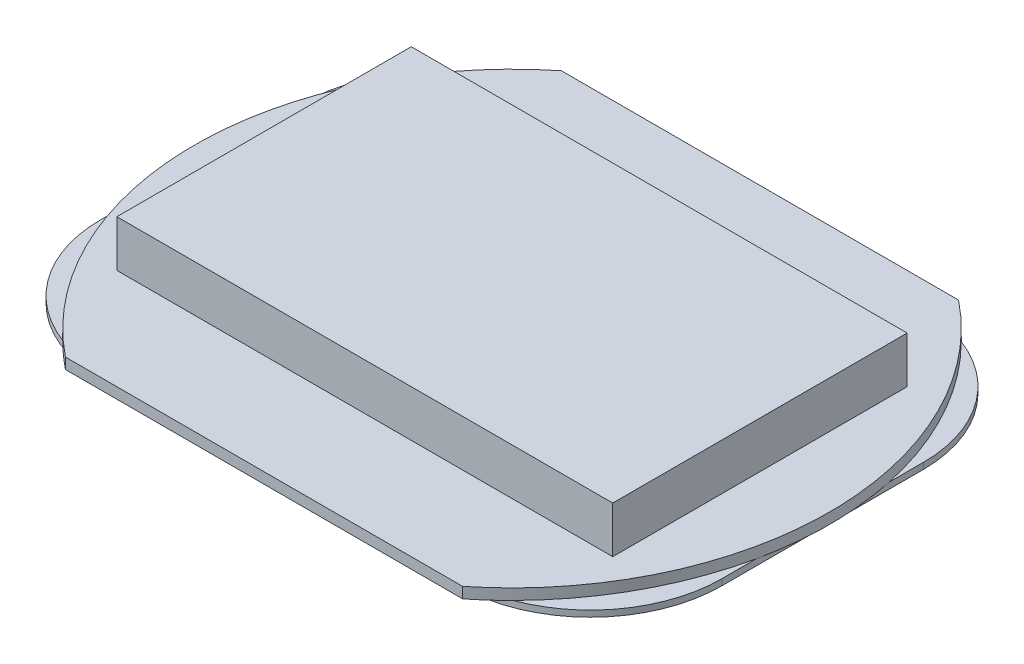
from build123d import *

# Parameters (mm, degrees)
EXTRUDE_1_DEPTH = 0.7
SKETCH_2_W      = 22
SKETCH_2_H      = 11
EXTRUDE_2_DEPTH = 0.4
SKETCH_3_W      = 32
SKETCH_3_H      = 19
EXTRUDE_3_DEPTH = 3


with BuildPart() as part:
    # Эскиз1 → Бобышка-Вытянуть1 (new body)
    with BuildSketch(Plane(origin=(0, 0, 0), x_dir=(1, 0, 0), z_dir=(0, 1, 0))):
        with BuildLine():
            Line((-12.816005618, 16), (12.816005618, 16))
            ThreePointArc((12.816005618, 16), (20.5, 0), (12.816005618, -16))
            Line((12.816005618, -16), (-12.816005618, -16))
            ThreePointArc((-12.816005618, -16), (-20.5, 0), (-12.816005618, 16))
        make_face()
    extrude(amount=EXTRUDE_1_DEPTH)

    # Эскиз2 → Бобышка-Вытянуть2 (add)
    with BuildSketch(Plane.XZ):
        with BuildLine():
            Line((-11.55, 15), (11.55, 15))
            ThreePointArc((11.55, 15), (17.56040764, 12.51040764), (20.05, 6.5))
            Line((20.05, 6.5), (20.05, -6.5))
            ThreePointArc((20.05, -6.5), (17.56040764, -12.51040764), (11.55, -15))
            Line((11.55, -15), (-11.55, -15))
            ThreePointArc((-11.55, -15), (-17.56040764, -12.51040764), (-20.05, -6.5))
            Line((-20.05, -6.5), (-20.05, 6.5))
            ThreePointArc((-20.05, 6.5), (-17.56040764, 12.51040764), (-11.55, 15))
        make_face()
        Rectangle(SKETCH_2_W, SKETCH_2_H, mode=Mode.SUBTRACT)
    extrude(amount=EXTRUDE_2_DEPTH)

    # Эскиз3 → Бобышка-Вытянуть3 (add)
    with BuildSketch(Plane(origin=(0, 0.7, 0), x_dir=(1, 0, 0), z_dir=(0, 1, 0))):
        Rectangle(SKETCH_3_W, SKETCH_3_H)
    extrude(amount=EXTRUDE_3_DEPTH)


solid = part.part
